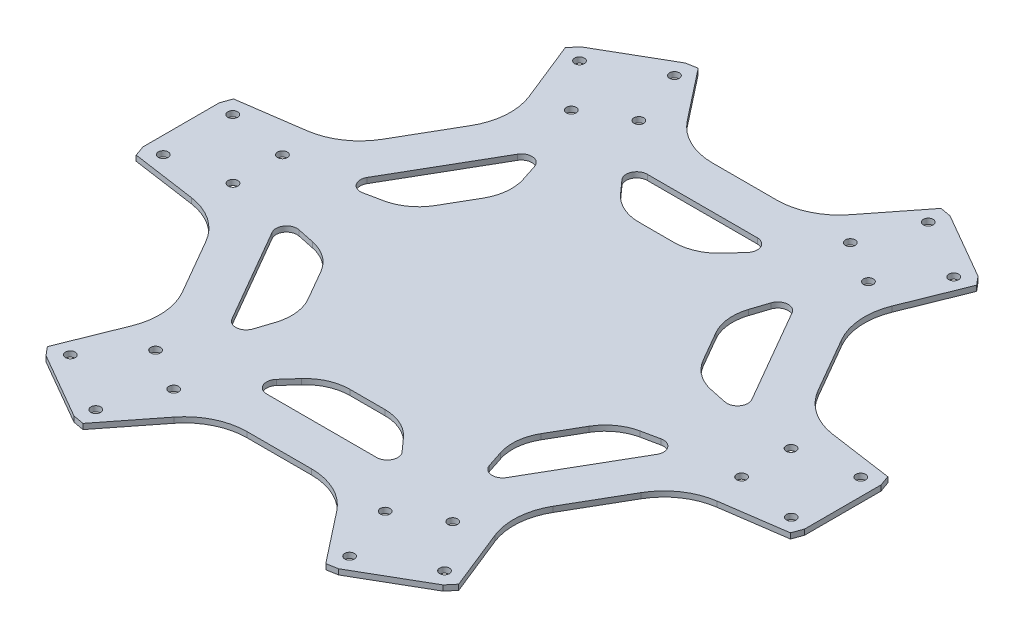
from build123d import *

# Parameters (mm, degrees)
MODEL_R             = 1.625
BOSS_EXTRUDE1_DEPTH = 1.8


with BuildPart() as part:
    # Model → Boss-Extrude1 (new body)
    with BuildSketch(Plane(origin=(0, 0, 0), x_dir=(1, 0, 0), z_dir=(0, 1, 0))):
        with BuildLine():
            Line((-40.455465124, -102.493878505), (-44.082941678, -101.852337067))
            Line((-44.082941678, -101.852337067), (-66.165240495, -89.1031159))
            Line((-66.165240495, -89.1031159), (-68.534569956, -86.282399772))
            Line((-68.534569956, -86.282399772), (-60.482983119, -66.206045102))
            ThreePointArc((-60.482983119, -66.206045102), (-59.040112281, -56.981399894), (-61.775650285, -48.054318215))
            Line((-61.775650285, -48.054318215), (-72.504085478, -29.472123375))
            ThreePointArc((-72.504085478, -29.472123375), (-78.867395992, -22.639537131), (-87.577608502, -19.276777327))
            Line((-87.577608502, -19.276777327), (-108.99003508, -16.211478733))
            Line((-108.99003508, -16.211478733), (-110.248182174, -12.749221166))
            Line((-110.248182174, -12.749221166), (-110.248182174, 12.749221166))
            Line((-110.248182174, 12.749221166), (-108.99003508, 16.211478733))
            Line((-108.99003508, 16.211478733), (-87.577608502, 19.276777327))
            ThreePointArc((-87.577608502, 19.276777327), (-78.867395992, 22.639537131), (-72.504085478, 29.472123375))
            Line((-72.504085478, 29.472123375), (-61.775650285, 48.054318215))
            ThreePointArc((-61.775650285, 48.054318215), (-59.040112281, 56.981399894), (-60.482983119, 66.206045102))
            Line((-60.482983119, 66.206045102), (-68.534569956, 86.282399772))
            Line((-68.534569956, 86.282399772), (-66.165240495, 89.1031159))
            Line((-66.165240495, 89.1031159), (-44.082941678, 101.852337067))
            Line((-44.082941678, 101.852337067), (-40.455465124, 102.493878505))
            Line((-40.455465124, 102.493878505), (-27.094625382, 85.482822428))
            ThreePointArc((-27.094625382, 85.482822428), (-19.82728371, 79.620937024), (-10.728435193, 77.52644159))
            Line((-10.728435193, 77.52644159), (10.728435194, 77.52644159))
            ThreePointArc((10.728435194, 77.52644159), (19.827283711, 79.620937024), (27.094625383, 85.482822428))
            Line((27.094625383, 85.482822428), (40.455465125, 102.493878505))
            Line((40.455465125, 102.493878505), (44.082941679, 101.852337067))
            Line((44.082941679, 101.852337067), (66.165240496, 89.1031159))
            Line((66.165240496, 89.1031159), (68.534569957, 86.282399772))
            Line((68.534569957, 86.282399772), (60.48298312, 66.206045102))
            ThreePointArc((60.48298312, 66.206045102), (59.040112282, 56.981399894), (61.775650286, 48.054318215))
            Line((61.775650286, 48.054318215), (72.504085479, 29.472123375))
            ThreePointArc((72.504085479, 29.472123375), (78.867395993, 22.639537131), (87.577608503, 19.276777327))
            Line((87.577608503, 19.276777327), (108.990035081, 16.211478733))
            Line((108.990035081, 16.211478733), (110.248182175, 12.749221166))
            Line((110.248182175, 12.749221166), (110.248182175, -12.749221166))
            Line((110.248182175, -12.749221166), (108.990035081, -16.211478733))
            Line((108.990035081, -16.211478733), (87.577608503, -19.276777327))
            ThreePointArc((87.577608503, -19.276777327), (78.867395993, -22.639537131), (72.504085479, -29.472123375))
            Line((72.504085479, -29.472123375), (61.775650286, -48.054318215))
            ThreePointArc((61.775650286, -48.054318215), (59.040112282, -56.981399894), (60.48298312, -66.206045102))
            Line((60.48298312, -66.206045102), (68.534569957, -86.282399772))
            Line((68.534569957, -86.282399772), (66.165240496, -89.1031159))
            Line((66.165240496, -89.1031159), (44.082941679, -101.852337067))
            Line((44.082941679, -101.852337067), (40.455465125, -102.493878505))
            Line((40.455465125, -102.493878505), (27.094625383, -85.482822428))
            ThreePointArc((27.094625383, -85.482822428), (19.827283711, -79.620937024), (10.728435194, -77.52644159))
            Line((10.728435194, -77.52644159), (-10.728435193, -77.52644159))
            ThreePointArc((-10.728435193, -77.52644159), (-19.82728371, -79.620937024), (-27.094625382, -85.482822428))
            Line((-27.094625382, -85.482822428), (-40.455465124, -102.493878505))
        make_face()
        with Locations((49.499854453, -69.261690272)):
            Circle(MODEL_R, mode=Mode.SUBTRACT)
        with Locations((35.232456058, -77.498976576)):
            Circle(MODEL_R, mode=Mode.SUBTRACT)
        with Locations((42.287869593, -96.400013533)):
            Circle(MODEL_R, mode=Mode.SUBTRACT)
        with Locations((62.340925848, -84.822376106)):
            Circle(MODEL_R, mode=Mode.SUBTRACT)
        with Locations((84.732310511, 8.237286304)):
            Circle(MODEL_R, mode=Mode.SUBTRACT)
        with Locations((84.732310511, -8.237286304)):
            Circle(MODEL_R, mode=Mode.SUBTRACT)
        with Locations((104.628795441, -11.577637427)):
            Circle(MODEL_R, mode=Mode.SUBTRACT)
        with Locations((104.628795441, 11.577637427)):
            Circle(MODEL_R, mode=Mode.SUBTRACT)
        with Locations((35.232456058, 77.498976576)):
            Circle(MODEL_R, mode=Mode.SUBTRACT)
        with Locations((49.499854453, 69.261690272)):
            Circle(MODEL_R, mode=Mode.SUBTRACT)
        with Locations((62.340925848, 84.822376106)):
            Circle(MODEL_R, mode=Mode.SUBTRACT)
        with Locations((42.287869593, 96.400013533)):
            Circle(MODEL_R, mode=Mode.SUBTRACT)
        with Locations((-49.499854453, 69.261690272)):
            Circle(MODEL_R, mode=Mode.SUBTRACT)
        with Locations((-35.232456058, 77.498976576)):
            Circle(MODEL_R, mode=Mode.SUBTRACT)
        with Locations((-42.287869593, 96.400013533)):
            Circle(MODEL_R, mode=Mode.SUBTRACT)
        with Locations((-62.340925848, 84.822376106)):
            Circle(MODEL_R, mode=Mode.SUBTRACT)
        with Locations((-84.732310511, -8.237286304)):
            Circle(MODEL_R, mode=Mode.SUBTRACT)
        with Locations((-84.732310511, 8.237286304)):
            Circle(MODEL_R, mode=Mode.SUBTRACT)
        with Locations((-104.628795441, 11.577637427)):
            Circle(MODEL_R, mode=Mode.SUBTRACT)
        with Locations((-104.628795441, -11.577637427)):
            Circle(MODEL_R, mode=Mode.SUBTRACT)
        with Locations((-35.232456058, -77.498976576)):
            Circle(MODEL_R, mode=Mode.SUBTRACT)
        with Locations((-49.499854453, -69.261690272)):
            Circle(MODEL_R, mode=Mode.SUBTRACT)
        with Locations((-62.340925848, -84.822376106)):
            Circle(MODEL_R, mode=Mode.SUBTRACT)
        with Locations((-42.287869593, -96.400013533)):
            Circle(MODEL_R, mode=Mode.SUBTRACT)
        with BuildLine():
            Line((18.345415848, -63.41189018), (-18.345415848, -63.41189018))
            ThreePointArc((-18.345415848, -63.41189018), (-21.541027318, -61.339499135), (-20.952320736, -57.576500083))
            Line((-20.952320736, -57.576500083), (-17.005197982, -53.170480885))
            ThreePointArc((-17.005197982, -53.170480885), (-11.951072558, -49.483817856), (-5.832748462, -48.179295586))
            Line((-5.832748462, -48.179295586), (5.832748462, -48.179295586))
            ThreePointArc((5.832748462, -48.179295586), (11.951072558, -49.483817856), (17.005197983, -53.170480885))
            Line((17.005197983, -53.170480885), (20.952320736, -57.576500083))
            ThreePointArc((20.952320736, -57.576500083), (21.541027318, -61.339499135), (18.345415848, -63.41189018))
        make_face(mode=Mode.SUBTRACT)
        with BuildLine():
            Line((64.089015721, -15.818348922), (45.743599874, -47.593541257))
            ThreePointArc((45.743599874, -47.593541257), (42.351050848, -49.324826449), (39.386551365, -46.933492067))
            Line((39.386551365, -46.933492067), (37.544388187, -41.312173892))
            ThreePointArc((37.544388187, -41.312173892), (36.87870706, -35.091841366), (38.808119683, -29.140956135))
            Line((38.808119683, -29.140956135), (44.640868145, -19.038339451))
            ThreePointArc((44.640868145, -19.038339451), (48.829779618, -14.39197649), (54.549586169, -11.858306993))
            Line((54.549586169, -11.858306993), (60.338872101, -10.643008016))
            ThreePointArc((60.338872101, -10.643008016), (63.892078166, -12.014672686), (64.089015721, -15.818348922))
        make_face(mode=Mode.SUBTRACT)
        with BuildLine():
            Line((45.743599874, 47.593541257), (64.089015721, 15.818348922))
            ThreePointArc((64.089015721, 15.818348922), (63.892078166, 12.014672686), (60.338872101, 10.643008016))
            Line((60.338872101, 10.643008016), (54.549586169, 11.858306993))
            ThreePointArc((54.549586169, 11.858306993), (48.829779618, 14.39197649), (44.640868145, 19.038339451))
            Line((44.640868145, 19.038339451), (38.808119683, 29.140956135))
            ThreePointArc((38.808119683, 29.140956135), (36.87870706, 35.091841366), (37.544388187, 41.312173892))
            Line((37.544388187, 41.312173892), (39.386551365, 46.933492067))
            ThreePointArc((39.386551365, 46.933492067), (42.351050848, 49.324826449), (45.743599874, 47.593541257))
        make_face(mode=Mode.SUBTRACT)
        with BuildLine():
            Line((-18.345415848, 63.41189018), (18.345415848, 63.41189018))
            ThreePointArc((18.345415848, 63.41189018), (21.541027318, 61.339499136), (20.952320736, 57.576500083))
            Line((20.952320736, 57.576500083), (17.005197982, 53.170480885))
            ThreePointArc((17.005197982, 53.170480885), (11.951072558, 49.483817856), (5.832748462, 48.179295586))
            Line((5.832748462, 48.179295586), (-5.832748462, 48.179295586))
            ThreePointArc((-5.832748462, 48.179295586), (-11.951072558, 49.483817856), (-17.005197983, 53.170480885))
            Line((-17.005197983, 53.170480885), (-20.952320736, 57.576500083))
            ThreePointArc((-20.952320736, 57.576500083), (-21.541027318, 61.339499136), (-18.345415848, 63.41189018))
        make_face(mode=Mode.SUBTRACT)
        with BuildLine():
            Line((-64.089015722, 15.818348923), (-45.743599874, 47.593541257))
            ThreePointArc((-45.743599874, 47.593541257), (-42.351050848, 49.324826449), (-39.386551365, 46.933492067))
            Line((-39.386551365, 46.933492067), (-37.544388187, 41.312173892))
            ThreePointArc((-37.544388187, 41.312173892), (-36.87870706, 35.091841366), (-38.808119683, 29.140956135))
            Line((-38.808119683, 29.140956135), (-44.640868145, 19.038339451))
            ThreePointArc((-44.640868145, 19.038339451), (-48.829779618, 14.39197649), (-54.549586169, 11.858306993))
            Line((-54.549586169, 11.858306993), (-60.338872101, 10.643008016))
            ThreePointArc((-60.338872101, 10.643008016), (-63.892078166, 12.014672686), (-64.089015722, 15.818348923))
        make_face(mode=Mode.SUBTRACT)
        with BuildLine():
            Line((-45.743599874, -47.593541257), (-64.089015722, -15.818348923))
            ThreePointArc((-64.089015722, -15.818348923), (-63.892078166, -12.014672686), (-60.338872101, -10.643008016))
            Line((-60.338872101, -10.643008016), (-54.549586169, -11.858306993))
            ThreePointArc((-54.549586169, -11.858306993), (-48.829779618, -14.39197649), (-44.640868145, -19.038339451))
            Line((-44.640868145, -19.038339451), (-38.808119683, -29.140956135))
            ThreePointArc((-38.808119683, -29.140956135), (-36.87870706, -35.091841366), (-37.544388187, -41.312173892))
            Line((-37.544388187, -41.312173892), (-39.386551365, -46.933492067))
            ThreePointArc((-39.386551365, -46.933492067), (-42.351050848, -49.324826449), (-45.743599874, -47.593541257))
        make_face(mode=Mode.SUBTRACT)
    extrude(amount=BOSS_EXTRUDE1_DEPTH)


solid = part.part
